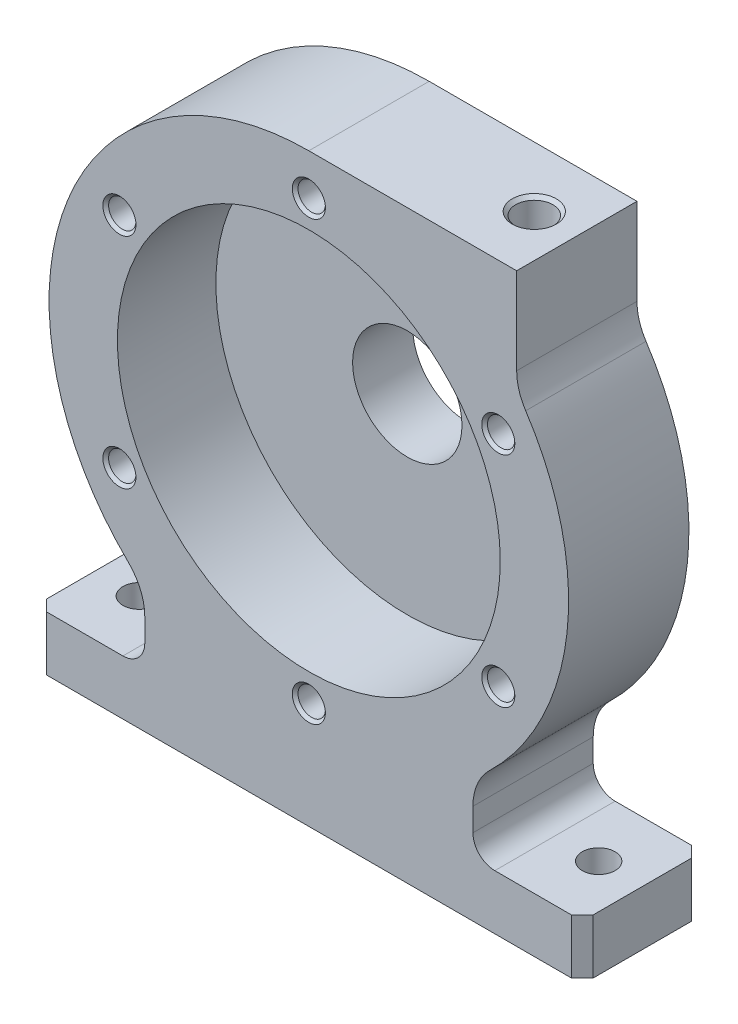
from build123d import *

# Parameters (mm, degrees)
BOSS_EXTRUDE1_DEPTH                                 = 22
SKETCH2_R                                           = 35
CUT_EXTRUDE1_DEPTH                                  = 18
SKETCH3_R                                           = 14
BOSS_EXTRUDE2_DEPTH                                 = 7
FILLET1_R                                           = 4
SKETCH4_R                                           = 10
CUT_EXTRUDE2_DEPTH                                  = 30
CHAMFER1_SIZE                                       = 2
M8X1_25_TAPPED_HOLE1_D                              = 6.8
M8X1_25_TAPPED_HOLE1_DEPTH                          = 29.75
M8X1_25_TAPPED_HOLE1_CSINK_D                        = 8.05
M8X1_25_TAPPED_HOLE1_CSINK_ANGLE                    = 90
M8X1_25_TAPPED_HOLE1_TIP                            = 2.042926105
CIRPATTERN1_COUNT                                   = 6
CSK_FOR_M8_COUNTERSUNK_FLAT_HEAD_SCREW1_D           = 6
CSK_FOR_M8_COUNTERSUNK_FLAT_HEAD_SCREW1_DEPTH       = 20
CSK_FOR_M8_COUNTERSUNK_FLAT_HEAD_SCREW1_CSINK_D     = 8
CSK_FOR_M8_COUNTERSUNK_FLAT_HEAD_SCREW1_CSINK_ANGLE = 90
CSK_FOR_M8_COUNTERSUNK_FLAT_HEAD_SCREW1_TIP         = 1.802581857


with BuildPart() as part:
    # Sketch1 → Boss-Extrude1 (new body)
    with BuildSketch(Plane.XY):
        with BuildLine():
            Line((-50, -59.5), (50, -59.5))
            Line((50, -59.5), (50, -49.5))
            Line((50, -49.5), (34, -49.5))
            ThreePointArc((34, -49.5), (31.171572875, -48.328427125), (30, -45.5))
            Line((30, -45.5), (30, -41.306779105))
            ThreePointArc((30, -41.306779105), (30.792252789, -37.405831617), (33.043478261, -34.122991434))
            ThreePointArc((33.043478261, -34.122991434), (47.217043986, -5.176944775), (39.652173913, 26.152535326))
            ThreePointArc((39.652173913, 26.152535326), (38.421945373, 28.784159388), (38, 31.658332237))
            Line((38, 31.658332237), (38, 47.5))
            Line((38, 47.5), (0, 47.5))
            ThreePointArc((0, 47.5), (-44.028922841, 17.824251834), (-33.043478261, -34.122991434))
            ThreePointArc((-33.043478261, -34.122991434), (-30.792252789, -37.405831617), (-30, -41.306779105))
            Line((-30, -41.306779105), (-30, -45.5))
            ThreePointArc((-30, -45.5), (-31.171572875, -48.328427125), (-34, -49.5))
            Line((-34, -49.5), (-50, -49.5))
            Line((-50, -49.5), (-50, -59.5))
        make_face()
    extrude(amount=BOSS_EXTRUDE1_DEPTH)

    # Sketch2 → Cut-Extrude1 (cut)
    with BuildSketch(Plane.XY.offset(22)):
        Circle(SKETCH2_R)
    extrude(amount=-CUT_EXTRUDE1_DEPTH, mode=Mode.SUBTRACT)

    # Sketch3 → Boss-Extrude2 (add)
    with BuildSketch(Plane(origin=(0, 0, 0), x_dir=(-1, 0, 0), z_dir=(0, 0, -1))):
        Circle(SKETCH3_R)
    extrude(amount=BOSS_EXTRUDE2_DEPTH)

    # Fillet1
    fillet1_edges = [part.edges().sort_by_distance(p)[0] for p in [
        (14, 0, 0),
    ]]
    fillet(fillet1_edges, radius=FILLET1_R)

    # Sketch4 → Cut-Extrude2 (cut, through all)
    with BuildSketch(Plane(origin=(0, 0, -7), x_dir=(-1, 0, 0), z_dir=(0, 0, -1))):
        Circle(SKETCH4_R)
    extrude(amount=-CUT_EXTRUDE2_DEPTH, mode=Mode.SUBTRACT)

    # Chamfer1
    chamfer1_edges = [part.edges().sort_by_distance(p)[0] for p in [
        (50, -54.5, 0),
        (-50, -54.5, 0),
        (-50, -54.5, 22),
        (50, -54.5, 22),
    ]]
    chamfer(chamfer1_edges, length=CHAMFER1_SIZE)

    # M8x1.25 Tapped Hole1
    with Locations(Plane(origin=(0, 47.5, 0), x_dir=(1, 0, 0), z_dir=(0, 1, 0))):
        with Locations((30.22415, -11)):
            CounterSinkHole(M8X1_25_TAPPED_HOLE1_D / 2, M8X1_25_TAPPED_HOLE1_CSINK_D / 2, depth=M8X1_25_TAPPED_HOLE1_DEPTH, counter_sink_angle=M8X1_25_TAPPED_HOLE1_CSINK_ANGLE)
            with Locations((0, 0, -(M8X1_25_TAPPED_HOLE1_DEPTH + M8X1_25_TAPPED_HOLE1_TIP / 2))):  # 118° drill point
                Cone(0, M8X1_25_TAPPED_HOLE1_D / 2, M8X1_25_TAPPED_HOLE1_TIP, mode=Mode.SUBTRACT)

    # Sketch10 → M6x1.0 Tapped Hole1 (revolve, cut)
    with BuildSketch(Plane(origin=(0, 40, 22), x_dir=(0, -1, 0), z_dir=(1, 0, 0))):
        Polygon((0, 0), (0, 16.502151548), (2.5, 15), (2.5, 0.525), (3.025, 0), align=None)
    m6x1_0_tapped_hole1 = revolve(axis=Axis((0, 40, 28.35), (0, 0, -1)), mode=Mode.SUBTRACT)

    # CirPattern1: M6x1.0 Tapped Hole1 ×6 about axis
    cirpattern1_axis = Axis((0, 0, 0), (0, 0, 1))
    for i in range(1, CIRPATTERN1_COUNT):
        add(m6x1_0_tapped_hole1.rotate(cirpattern1_axis, i * 360 / CIRPATTERN1_COUNT), mode=Mode.SUBTRACT)

    # CSK for M8 Countersunk Flat Head Screw1
    with Locations(Plane(origin=(0, -59.5, 0), x_dir=(-1, 0, 0), z_dir=(0, -1, 0))):
        with Locations((42, -11), (-42, -11)):
            CounterSinkHole(CSK_FOR_M8_COUNTERSUNK_FLAT_HEAD_SCREW1_D / 2, CSK_FOR_M8_COUNTERSUNK_FLAT_HEAD_SCREW1_CSINK_D / 2, depth=CSK_FOR_M8_COUNTERSUNK_FLAT_HEAD_SCREW1_DEPTH, counter_sink_angle=CSK_FOR_M8_COUNTERSUNK_FLAT_HEAD_SCREW1_CSINK_ANGLE)
            with Locations((0, 0, -(CSK_FOR_M8_COUNTERSUNK_FLAT_HEAD_SCREW1_DEPTH + CSK_FOR_M8_COUNTERSUNK_FLAT_HEAD_SCREW1_TIP / 2))):  # 118° drill point
                Cone(0, CSK_FOR_M8_COUNTERSUNK_FLAT_HEAD_SCREW1_D / 2, CSK_FOR_M8_COUNTERSUNK_FLAT_HEAD_SCREW1_TIP, mode=Mode.SUBTRACT)


solid = part.part
